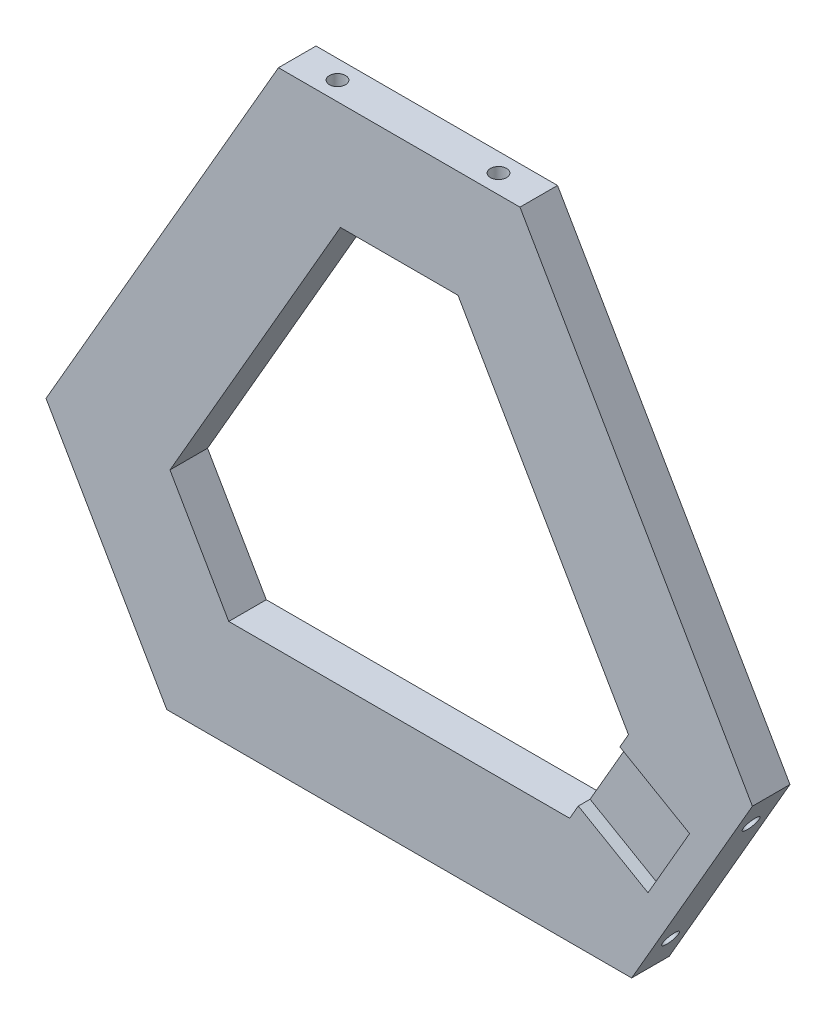
from build123d import *

# Parameters (mm, degrees)
EXTRUDE_1_DEPTH     = 7
SKETCH_12_R         = 1.5
CUT_EXTRUDE_1_DEPTH = 12
SKETCH_13_R         = 1.5
CUT_EXTRUDE_2_DEPTH = 12
SKETCH_14_R         = 1.5
CUT_EXTRUDE_3_DEPTH = 12
CUT_EXTRUDE_4_DEPTH = 8
CUT_EXTRUDE_5_DEPTH = 2.2
CUT_EXTRUDE_6_DEPTH = 5.8


with BuildPart() as part:
    # 草圖1 → 填料-伸長1 (new body)
    with BuildSketch(Plane.XY):
        Polygon((-22.5, 63), (22.5, 63), (65.809600438, -12.014428415), (43.309600438, -50.985571585), (-43.309600438, -50.985571585), (-65.809600438, -12.014428415), align=None)
    extrude(amount=EXTRUDE_1_DEPTH)

    # 草圖12 → 除料-伸長1 (cut)
    with BuildSketch(Plane(origin=(-54.559600438, -31.5, 0), x_dir=(0, 0, 1), z_dir=(-0.866025404, -0.5, 0))):
        with Locations((3.5, 15)):
            Circle(SKETCH_12_R)
        with Locations((3.5, -15)):
            Circle(SKETCH_12_R)
    extrude(amount=-CUT_EXTRUDE_1_DEPTH, mode=Mode.SUBTRACT)

    # 草圖13 → 除料-伸長2 (cut)
    with BuildSketch(Plane(origin=(54.559600438, -31.5, 0), x_dir=(0, 0, -1), z_dir=(0.866025404, -0.5, 0))):
        with Locations((-3.5, 15)):
            Circle(SKETCH_13_R)
        with Locations((-3.5, -15)):
            Circle(SKETCH_13_R)
    extrude(amount=-CUT_EXTRUDE_2_DEPTH, mode=Mode.SUBTRACT)

    # 草圖14 → 除料-伸長3 (cut)
    with BuildSketch(Plane(origin=(0, 63, 0), x_dir=(1, 0, 0), z_dir=(0, 1, 0))):
        with Locations((-15, -3.5)):
            Circle(SKETCH_14_R)
        with Locations((15, -3.5)):
            Circle(SKETCH_14_R)
    extrude(amount=-CUT_EXTRUDE_3_DEPTH, mode=Mode.SUBTRACT)

    # 草圖15 → 除料-伸長4 (cut, through all)
    with BuildSketch(Plane.XY.offset(7)):
        Polygon((31.762595055, -30.985571585), (42.715589671, -12.014428415), (10.952994616, 43), (-10.952994616, 43), (-42.715589671, -12.014428415), (-31.762595055, -30.985571585), align=None)
    extrude(amount=-CUT_EXTRUDE_4_DEPTH, mode=Mode.SUBTRACT)

    # 草圖16 → 除料-伸長5 (cut)
    with BuildSketch(Plane.XY.offset(7)):
        Polygon((41.114092363, -14.788303121), (54.104473419, -22.288303121), (46.354473419, -35.711696879), (33.364092363, -28.211696879), align=None)
    extrude(amount=-CUT_EXTRUDE_5_DEPTH, mode=Mode.SUBTRACT)

    # 草圖17 → 除料-伸長6 (cut, through all)
    with BuildSketch(Plane.XY.offset(4.8)):
        Polygon((41.114092363, -14.788303121), (39.714092363, -17.213174251), (52.704473419, -24.713174251), (54.104473419, -22.288303121), align=None)
    extrude(amount=-CUT_EXTRUDE_6_DEPTH, mode=Mode.SUBTRACT)


solid = part.part
